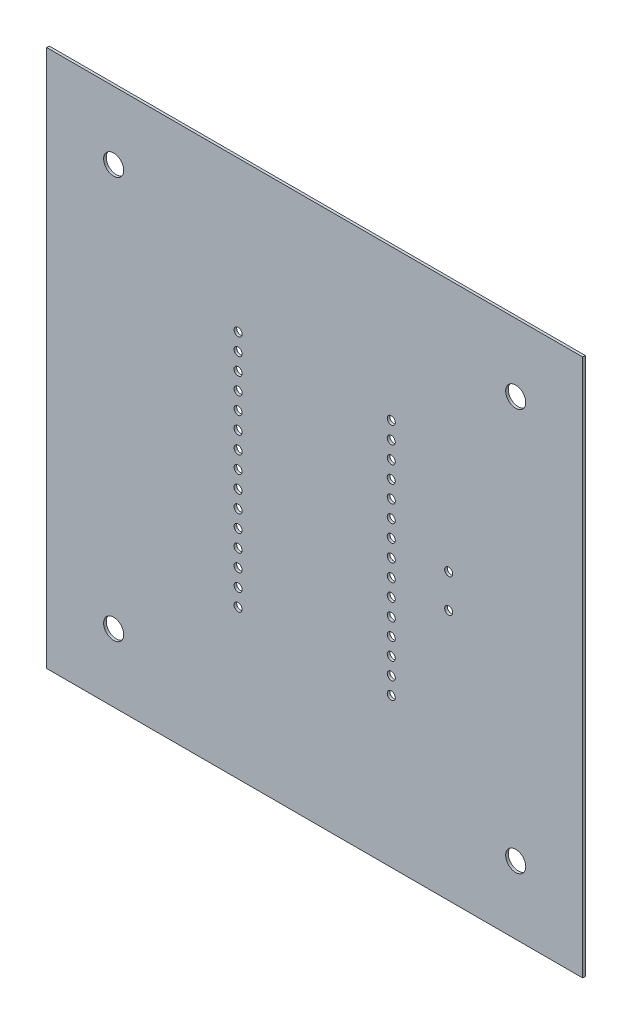
from build123d import *

# Parameters (mm, degrees)
BOARD_DEPTH                 = 0.39116
ESBO_O2_R                   = 0.6
HOLE_P1_1_DEPTH             = 0.39116
ESBO_O3_R                   = 0.6
HOLE_P1_2_DEPTH             = 1.39116
ESBO_O4_R                   = 0.6
HOLE_P3_12_DEPTH            = 1.39116
ESBO_O5_R                   = 0.6
HOLE_P3_13_DEPTH            = 1.39116
ESBO_O6_R                   = 0.6
HOLE_P3_14_DEPTH            = 1.39116
ESBO_O7_R                   = 0.6
HOLE_P3_15_DEPTH            = 1.39116
ESBO_O8_R                   = 0.6
HOLE_P3_11_DEPTH            = 1.39116
ESBO_O9_R                   = 0.6
HOLE_P3_10_DEPTH            = 1.39116
ESBO_O10_R                  = 0.6
HOLE_P3_9_DEPTH             = 1.39116
ESBO_O11_R                  = 0.6
HOLE_P3_8_DEPTH             = 1.39116
ESBO_O12_R                  = 0.6
HOLE_P3_7_DEPTH             = 1.39116
ESBO_O13_R                  = 0.6
HOLE_P3_6_DEPTH             = 1.39116
ESBO_O14_R                  = 0.6
HOLE_P3_5_DEPTH             = 1.39116
ESBO_O15_R                  = 0.6
HOLE_P3_1_DEPTH             = 1.39116
ESBO_O16_R                  = 0.6
HOLE_P3_2_DEPTH             = 1.39116
ESBO_O17_R                  = 0.6
HOLE_P3_3_DEPTH             = 1.39116
ESBO_O18_R                  = 0.6
HOLE_P3_4_DEPTH             = 1.39116
ESBO_O19_R                  = 0.6
HOLE_P2_12_DEPTH            = 1.39116
ESBO_O20_R                  = 0.6
HOLE_P2_13_DEPTH            = 1.39116
ESBO_O21_R                  = 0.6
HOLE_P2_14_DEPTH            = 1.39116
ESBO_O22_R                  = 0.6
HOLE_P2_15_DEPTH            = 1.39116
ESBO_O23_R                  = 0.6
HOLE_P2_11_DEPTH            = 1.39116
ESBO_O24_R                  = 0.6
HOLE_P2_10_DEPTH            = 1.39116
ESBO_O25_R                  = 0.6
HOLE_P2_9_DEPTH             = 1.39116
ESBO_O26_R                  = 0.6
HOLE_P2_8_DEPTH             = 1.39116
ESBO_O27_R                  = 0.6
HOLE_P2_7_DEPTH             = 1.39116
ESBO_O28_R                  = 0.6
HOLE_P2_6_DEPTH             = 1.39116
ESBO_O29_R                  = 0.6
HOLE_P2_5_DEPTH             = 1.39116
ESBO_O30_R                  = 0.6
HOLE_P2_1_DEPTH             = 1.39116
ESBO_O31_R                  = 0.6
HOLE_P2_2_DEPTH             = 1.39116
ESBO_O32_R                  = 0.6
HOLE_P2_3_DEPTH             = 1.39116
ESBO_O33_R                  = 0.6
HOLE_P2_4_DEPTH             = 1.39116
ESBO_O34_R                  = 1.5
FREE_CORTE_EXTRUS_O33_DEPTH = 10


with BuildPart() as part:
    # Esboço1 → Board (new body)
    with BuildSketch(Plane.XY):
        Polygon((0, 0), (80.00499, 0), (80.00499, 80.25899), (0, 80.259), align=None)
    extrude(amount=BOARD_DEPTH)

    # Esboço2 → Hole - P1-1 (cut)
    with BuildSketch(Plane.XY.offset(0.39116)):
        with Locations((60, 37.5)):
            Circle(ESBO_O2_R)
    extrude(amount=-HOLE_P1_1_DEPTH, mode=Mode.SUBTRACT)

    # Esboço3 → Hole - P1-2 (cut, through all)
    with BuildSketch(Plane.XY.offset(0.39116)):
        with Locations((60, 42.5)):
            Circle(ESBO_O3_R)
    extrude(amount=-HOLE_P1_2_DEPTH, mode=Mode.SUBTRACT)

    # Esboço4 → Hole - P3-12 (cut, through all)
    with BuildSketch(Plane.XY.offset(0.39116)):
        with Locations((51.43, 50.16)):
            Circle(ESBO_O4_R)
    extrude(amount=-HOLE_P3_12_DEPTH, mode=Mode.SUBTRACT)

    # Esboço5 → Hole - P3-13 (cut, through all)
    with BuildSketch(Plane.XY.offset(0.39116)):
        with Locations((51.43, 52.7)):
            Circle(ESBO_O5_R)
    extrude(amount=-HOLE_P3_13_DEPTH, mode=Mode.SUBTRACT)

    # Esboço6 → Hole - P3-14 (cut, through all)
    with BuildSketch(Plane.XY.offset(0.39116)):
        with Locations((51.43, 55.24)):
            Circle(ESBO_O6_R)
    extrude(amount=-HOLE_P3_14_DEPTH, mode=Mode.SUBTRACT)

    # Esboço7 → Hole - P3-15 (cut, through all)
    with BuildSketch(Plane.XY.offset(0.39116)):
        with Locations((51.43, 57.78)):
            Circle(ESBO_O7_R)
    extrude(amount=-HOLE_P3_15_DEPTH, mode=Mode.SUBTRACT)

    # Esboço8 → Hole - P3-11 (cut, through all)
    with BuildSketch(Plane.XY.offset(0.39116)):
        with Locations((51.43, 47.62)):
            Circle(ESBO_O8_R)
    extrude(amount=-HOLE_P3_11_DEPTH, mode=Mode.SUBTRACT)

    # Esboço9 → Hole - P3-10 (cut, through all)
    with BuildSketch(Plane.XY.offset(0.39116)):
        with Locations((51.43, 45.08)):
            Circle(ESBO_O9_R)
    extrude(amount=-HOLE_P3_10_DEPTH, mode=Mode.SUBTRACT)

    # Esboço10 → Hole - P3-9 (cut, through all)
    with BuildSketch(Plane.XY.offset(0.39116)):
        with Locations((51.43, 42.54)):
            Circle(ESBO_O10_R)
    extrude(amount=-HOLE_P3_9_DEPTH, mode=Mode.SUBTRACT)

    # Esboço11 → Hole - P3-8 (cut, through all)
    with BuildSketch(Plane.XY.offset(0.39116)):
        with Locations((51.43, 40)):
            Circle(ESBO_O11_R)
    extrude(amount=-HOLE_P3_8_DEPTH, mode=Mode.SUBTRACT)

    # Esboço12 → Hole - P3-7 (cut, through all)
    with BuildSketch(Plane.XY.offset(0.39116)):
        with Locations((51.43, 37.46)):
            Circle(ESBO_O12_R)
    extrude(amount=-HOLE_P3_7_DEPTH, mode=Mode.SUBTRACT)

    # Esboço13 → Hole - P3-6 (cut, through all)
    with BuildSketch(Plane.XY.offset(0.39116)):
        with Locations((51.43, 34.92)):
            Circle(ESBO_O13_R)
    extrude(amount=-HOLE_P3_6_DEPTH, mode=Mode.SUBTRACT)

    # Esboço14 → Hole - P3-5 (cut, through all)
    with BuildSketch(Plane.XY.offset(0.39116)):
        with Locations((51.43, 32.38)):
            Circle(ESBO_O14_R)
    extrude(amount=-HOLE_P3_5_DEPTH, mode=Mode.SUBTRACT)

    # Esboço15 → Hole - P3-1 (cut, through all)
    with BuildSketch(Plane.XY.offset(0.39116)):
        with Locations((51.43, 22.22)):
            Circle(ESBO_O15_R)
    extrude(amount=-HOLE_P3_1_DEPTH, mode=Mode.SUBTRACT)

    # Esboço16 → Hole - P3-2 (cut, through all)
    with BuildSketch(Plane.XY.offset(0.39116)):
        with Locations((51.43, 24.76)):
            Circle(ESBO_O16_R)
    extrude(amount=-HOLE_P3_2_DEPTH, mode=Mode.SUBTRACT)

    # Esboço17 → Hole - P3-3 (cut, through all)
    with BuildSketch(Plane.XY.offset(0.39116)):
        with Locations((51.43, 27.3)):
            Circle(ESBO_O17_R)
    extrude(amount=-HOLE_P3_3_DEPTH, mode=Mode.SUBTRACT)

    # Esboço18 → Hole - P3-4 (cut, through all)
    with BuildSketch(Plane.XY.offset(0.39116)):
        with Locations((51.43, 29.84)):
            Circle(ESBO_O18_R)
    extrude(amount=-HOLE_P3_4_DEPTH, mode=Mode.SUBTRACT)

    # Esboço19 → Hole - P2-12 (cut, through all)
    with BuildSketch(Plane.XY.offset(0.39116)):
        with Locations((28.57, 50.16)):
            Circle(ESBO_O19_R)
    extrude(amount=-HOLE_P2_12_DEPTH, mode=Mode.SUBTRACT)

    # Esboço20 → Hole - P2-13 (cut, through all)
    with BuildSketch(Plane.XY.offset(0.39116)):
        with Locations((28.57, 52.7)):
            Circle(ESBO_O20_R)
    extrude(amount=-HOLE_P2_13_DEPTH, mode=Mode.SUBTRACT)

    # Esboço21 → Hole - P2-14 (cut, through all)
    with BuildSketch(Plane.XY.offset(0.39116)):
        with Locations((28.57, 55.24)):
            Circle(ESBO_O21_R)
    extrude(amount=-HOLE_P2_14_DEPTH, mode=Mode.SUBTRACT)

    # Esboço22 → Hole - P2-15 (cut, through all)
    with BuildSketch(Plane.XY.offset(0.39116)):
        with Locations((28.57, 57.78)):
            Circle(ESBO_O22_R)
    extrude(amount=-HOLE_P2_15_DEPTH, mode=Mode.SUBTRACT)

    # Esboço23 → Hole - P2-11 (cut, through all)
    with BuildSketch(Plane.XY.offset(0.39116)):
        with Locations((28.57, 47.62)):
            Circle(ESBO_O23_R)
    extrude(amount=-HOLE_P2_11_DEPTH, mode=Mode.SUBTRACT)

    # Esboço24 → Hole - P2-10 (cut, through all)
    with BuildSketch(Plane.XY.offset(0.39116)):
        with Locations((28.57, 45.08)):
            Circle(ESBO_O24_R)
    extrude(amount=-HOLE_P2_10_DEPTH, mode=Mode.SUBTRACT)

    # Esboço25 → Hole - P2-9 (cut, through all)
    with BuildSketch(Plane.XY.offset(0.39116)):
        with Locations((28.57, 42.54)):
            Circle(ESBO_O25_R)
    extrude(amount=-HOLE_P2_9_DEPTH, mode=Mode.SUBTRACT)

    # Esboço26 → Hole - P2-8 (cut, through all)
    with BuildSketch(Plane.XY.offset(0.39116)):
        with Locations((28.57, 40)):
            Circle(ESBO_O26_R)
    extrude(amount=-HOLE_P2_8_DEPTH, mode=Mode.SUBTRACT)

    # Esboço27 → Hole - P2-7 (cut, through all)
    with BuildSketch(Plane.XY.offset(0.39116)):
        with Locations((28.57, 37.46)):
            Circle(ESBO_O27_R)
    extrude(amount=-HOLE_P2_7_DEPTH, mode=Mode.SUBTRACT)

    # Esboço28 → Hole - P2-6 (cut, through all)
    with BuildSketch(Plane.XY.offset(0.39116)):
        with Locations((28.57, 34.92)):
            Circle(ESBO_O28_R)
    extrude(amount=-HOLE_P2_6_DEPTH, mode=Mode.SUBTRACT)

    # Esboço29 → Hole - P2-5 (cut, through all)
    with BuildSketch(Plane.XY.offset(0.39116)):
        with Locations((28.57, 32.38)):
            Circle(ESBO_O29_R)
    extrude(amount=-HOLE_P2_5_DEPTH, mode=Mode.SUBTRACT)

    # Esboço30 → Hole - P2-1 (cut, through all)
    with BuildSketch(Plane.XY.offset(0.39116)):
        with Locations((28.57, 22.22)):
            Circle(ESBO_O30_R)
    extrude(amount=-HOLE_P2_1_DEPTH, mode=Mode.SUBTRACT)

    # Esboço31 → Hole - P2-2 (cut, through all)
    with BuildSketch(Plane.XY.offset(0.39116)):
        with Locations((28.57, 24.76)):
            Circle(ESBO_O31_R)
    extrude(amount=-HOLE_P2_2_DEPTH, mode=Mode.SUBTRACT)

    # Esboço32 → Hole - P2-3 (cut, through all)
    with BuildSketch(Plane.XY.offset(0.39116)):
        with Locations((28.57, 27.3)):
            Circle(ESBO_O32_R)
    extrude(amount=-HOLE_P2_3_DEPTH, mode=Mode.SUBTRACT)

    # Esboço33 → Hole - P2-4 (cut, through all)
    with BuildSketch(Plane.XY.offset(0.39116)):
        with Locations((28.57, 29.84)):
            Circle(ESBO_O33_R)
    extrude(amount=-HOLE_P2_4_DEPTH, mode=Mode.SUBTRACT)

    # Esboço34 → Free-Corte-extrusão33 (cut)
    with BuildSketch(Plane.XY.offset(0.39116)):
        with Locations((10.002495, 70.129495)):
            Circle(ESBO_O34_R)
        with Locations((70.002495, 70.129495)):
            Circle(ESBO_O34_R)
        with Locations((70.002495, 10.129495)):
            Circle(ESBO_O34_R)
        with Locations((10.002495, 10.129495)):
            Circle(ESBO_O34_R)
    extrude(amount=-FREE_CORTE_EXTRUS_O33_DEPTH, mode=Mode.SUBTRACT)


solid = part.part
